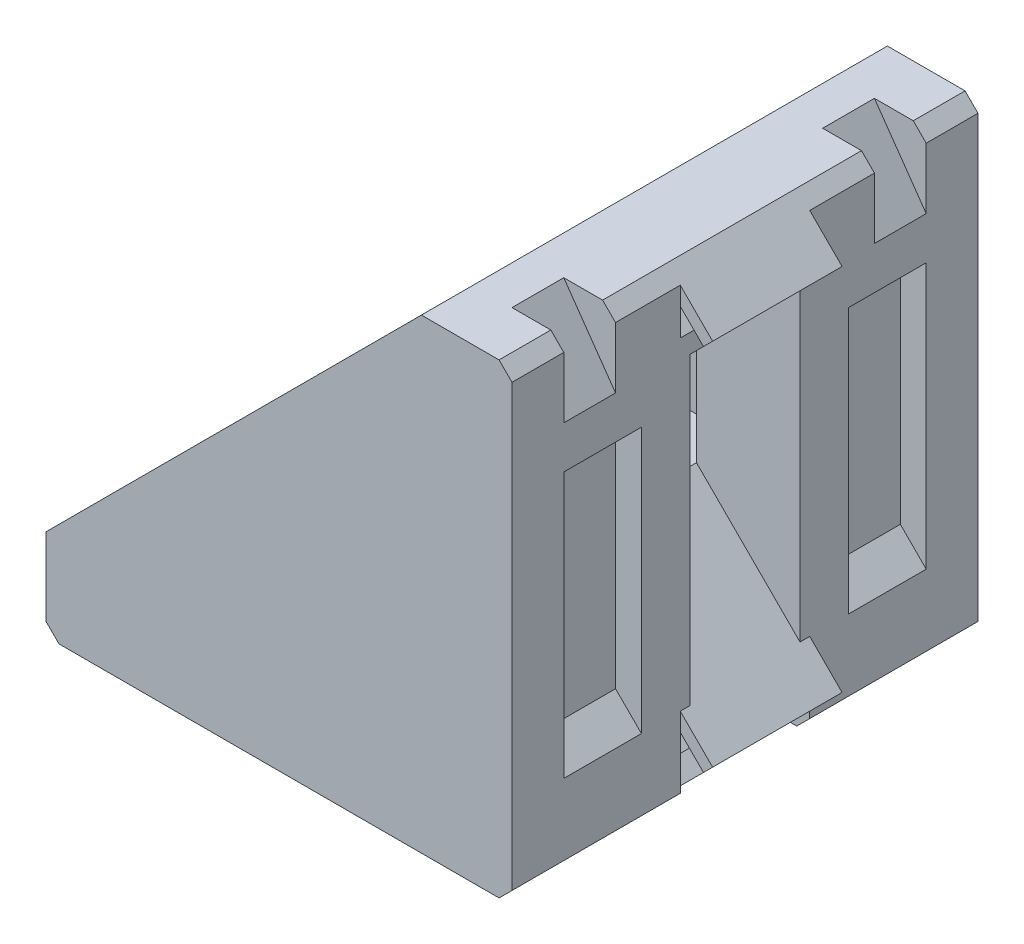
from build123d import *

# Parameters (mm, degrees)
EXTRUDE_1_DEPTH     = 5
EXTRUDE_1_2_DEPTH   = 5
EXTRUDE_1_3_DEPTH   = 5
EXTRUDE_2_DEPTH     = 13
EXTRUDE_3_DEPTH     = 0.75
CUT_EXTRUDE_1_DEPTH = 6
CUT_EXTRUDE_2_DEPTH = 4
EXTRUDE_5_DEPTH     = 4
CHAMFER_1_SIZE      = 1


with BuildPart() as part:
    # 草图1 → 拉伸1 (new body)
    with BuildSketch(Plane.XY):
        Polygon((21.49998914, 95.432607267), (27.49998914, 89.432607267), (29.49998914, 87.432607267), (31.99998914, 84.932607267), (32.707095921, 85.639714048), (30.914202702, 87.432607267), (30.207095921, 88.139714048), (31.689328968, 89.621947095), (33.103542531, 88.207733533), (35.224862874, 90.329053877), (33.810649312, 91.743267439), (35.292882359, 93.225500486), (35.99998914, 92.518393705), (37.792882359, 90.725500486), (38.49998914, 91.432607267), (35.99998914, 93.932607267), (33.99998914, 95.932607267), (27.99998914, 101.932607267), (27.99998914, 95.432607267), align=None)
    extrude(amount=EXTRUDE_1_DEPTH)



with BuildPart() as body_2:
    # 草图1 → Extrude 1 2 (new body)
    with BuildSketch(Plane.XY):
        Polygon((5.99998914, 87.432607267), (5.99998914, 95.432607267), (0.99998914, 95.432607267), (-1.086e-05, 94.432607267), (-1.086e-05, 88.432607267), (0.99998914, 87.432607267), (3.49998914, 84.932607267), (4.207095921, 85.639714048), (2.414202702, 87.432607267), (1.707095921, 88.139714048), (2.767756093, 89.20037422), (4.535523046, 87.432607267), align=None)
    extrude(amount=EXTRUDE_1_2_DEPTH)


with BuildPart() as body_3:
    # 草图1 → Extrude 1 3 (new body)
    with BuildSketch(Plane.XY):
        Polygon((27.99998914, 117.432607267), (35.99998914, 117.432607267), (35.99998914, 118.897073361), (34.232222187, 120.664840314), (35.292882359, 121.725500486), (35.99998914, 121.018393705), (37.792882359, 119.225500486), (38.49998914, 119.932607267), (35.99998914, 122.432607267), (34.99998914, 123.432607267), (28.99998914, 123.432607267), (27.99998914, 122.432607267), align=None)
    extrude(amount=EXTRUDE_1_3_DEPTH)


with BuildPart() as part_1:
    add(part.part)

    add(body_2.part)  # 拉伸2 merges body 2

    add(body_3.part)  # 拉伸2 merges body 3
    # 草图2 → 拉伸2 (add)
    with BuildSketch(Plane.XY.offset(5)):
        Polygon((34.99998914, 123.432607267), (28.99998914, 123.432607267), (27.99998914, 122.432607267), (27.99998914, 95.432607267), (0.99998914, 95.432607267), (-1.086e-05, 94.432607267), (-1.086e-05, 88.432607267), (0.99998914, 87.432607267), (35.99998914, 87.432607267), (35.99998914, 122.432607267), align=None)
    extrude(amount=EXTRUDE_2_DEPTH)

    # 草图3 → 拉伸3 (add)
    with BuildSketch(Plane(origin=(0, 0, 5), x_dir=(-1, 0, 0), z_dir=(0, 0, -1))):
        Polygon((-27.99998914, 117.432607267), (-35.99998914, 117.432607267), (-35.99998914, 93.932607267), (-27.99998914, 101.932607267), align=None)
    extrude_3 = extrude(amount=EXTRUDE_3_DEPTH)

    # 镜向1: 拉伸3 across plane
    add(extrude_3.mirror(Plane(origin=(61.716298204, 61.716298204, 0), x_dir=(0, 0, 1), z_dir=(-0.707106781, -0.707106781, 0))))

    # 草图4 → 切除-拉伸1 (cut)
    with BuildSketch(Plane.XY.offset(14)):
        Polygon((33.99998914, 114.432607267), (35.99998914, 114.432607267), (35.99998914, 93.932607267), (33.99998914, 95.932607267), align=None)
    cut_extrude_1 = extrude(amount=-CUT_EXTRUDE_1_DEPTH, mode=Mode.SUBTRACT)

    # 草图6 → 切除-拉伸2 (cut)
    with BuildSketch(Plane.XY.offset(14)):
        Polygon((31.99998914, 123.432607267), (34.99998914, 123.432607267), (35.99998914, 122.432607267), (35.99998914, 117.72001524), align=None)
    cut_extrude_2 = extrude(amount=-CUT_EXTRUDE_2_DEPTH, mode=Mode.SUBTRACT)

    # 镜向2: 切除-拉伸1, 切除-拉伸2 across plane
    add(cut_extrude_1.mirror(Plane(origin=(61.716298204, 61.716298204, 0), x_dir=(0, 0, 1), z_dir=(-0.707106781, -0.707106781, 0))), mode=Mode.SUBTRACT)
    add(cut_extrude_2.mirror(Plane(origin=(61.716298204, 61.716298204, 0), x_dir=(0, 0, 1), z_dir=(-0.707106781, -0.707106781, 0))), mode=Mode.SUBTRACT)

    # 草图7 → 拉伸5 (add)
    with BuildSketch(Plane.XY.offset(18)):
        Polygon((0.99998914, 95.432607267), (27.99998914, 95.432607267), (27.99998914, 122.432607267), align=None)
    extrude(amount=-EXTRUDE_5_DEPTH)

    # 镜向4: part across plane


with BuildPart() as part_2:
    add(part_1.part)
    add(part_1.part.mirror(Plane(origin=(0, 0, 0), x_dir=(1, 0, 0), z_dir=(0, 0, -1))))

    # 倒角1
    chamfer_1_edges = [part_2.edges().sort_by_distance(p)[0] for p in [
        (35.99998914, 87.432607267, -11.5),
        (35.99998914, 87.432607267, 11.5),
    ]]
    chamfer(chamfer_1_edges, length=CHAMFER_1_SIZE)


solid = part_2.part
